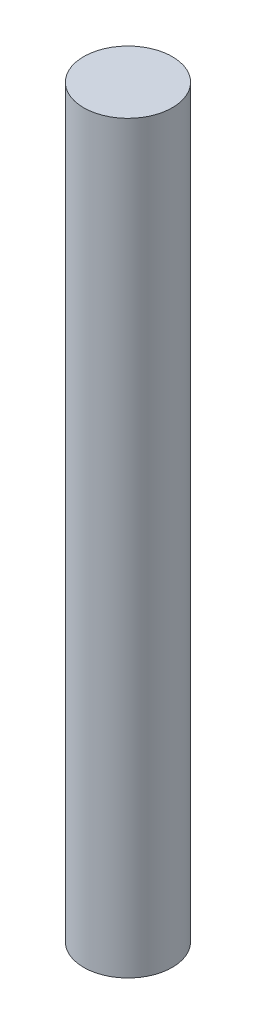
from build123d import *

# Parameters (mm, degrees)
SKETCH1_R           = 2.38
BOSS_EXTRUDE1_DEPTH = 40


with BuildPart() as part:
    # Sketch1 → Boss-Extrude1 (new body)
    with BuildSketch(Plane(origin=(0, 0, 0), x_dir=(1, 0, 0), z_dir=(0, 1, 0))):
        with Locations(Location((0, 0, 0), (0, 0, 270))):  # turned: the seam where the file's is
            Circle(SKETCH1_R)
    extrude(amount=BOSS_EXTRUDE1_DEPTH)


solid = part.part
